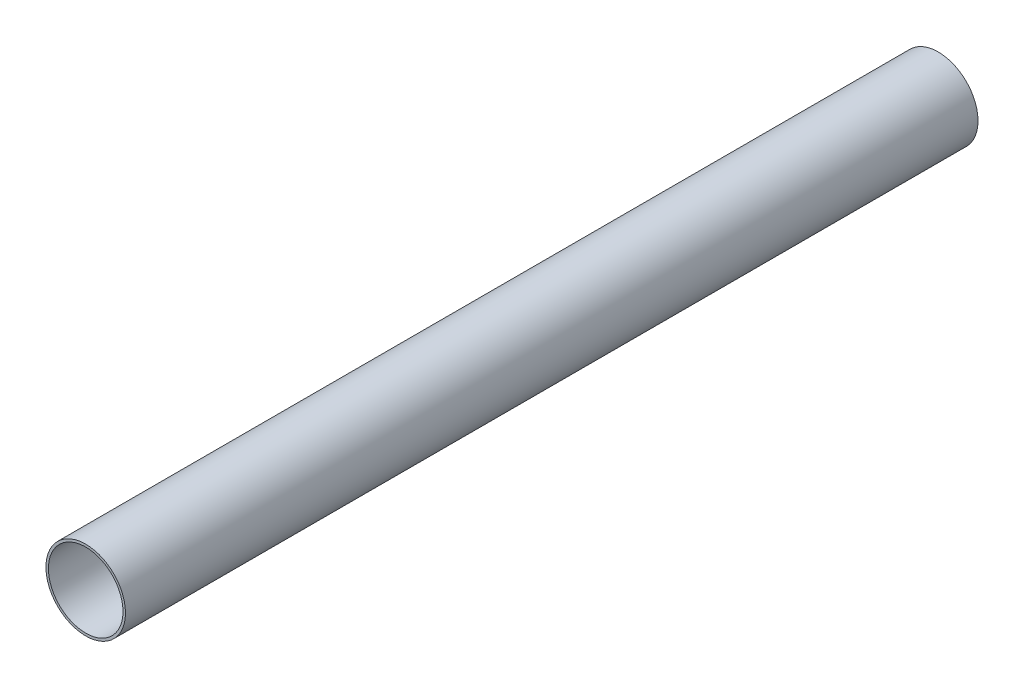
from build123d import *

# Parameters (mm, degrees)
SKETCH1_R           = 23.6982
SKETCH1_R_2         = 22.225
BOSS_EXTRUDE1_DEPTH = 508


with BuildPart() as part:
    # Sketch1 → Boss-Extrude1 (new body)
    with BuildSketch(Plane.XY):
        Circle(SKETCH1_R)
        Circle(SKETCH1_R_2, mode=Mode.SUBTRACT)
    extrude(amount=BOSS_EXTRUDE1_DEPTH)


solid = part.part
